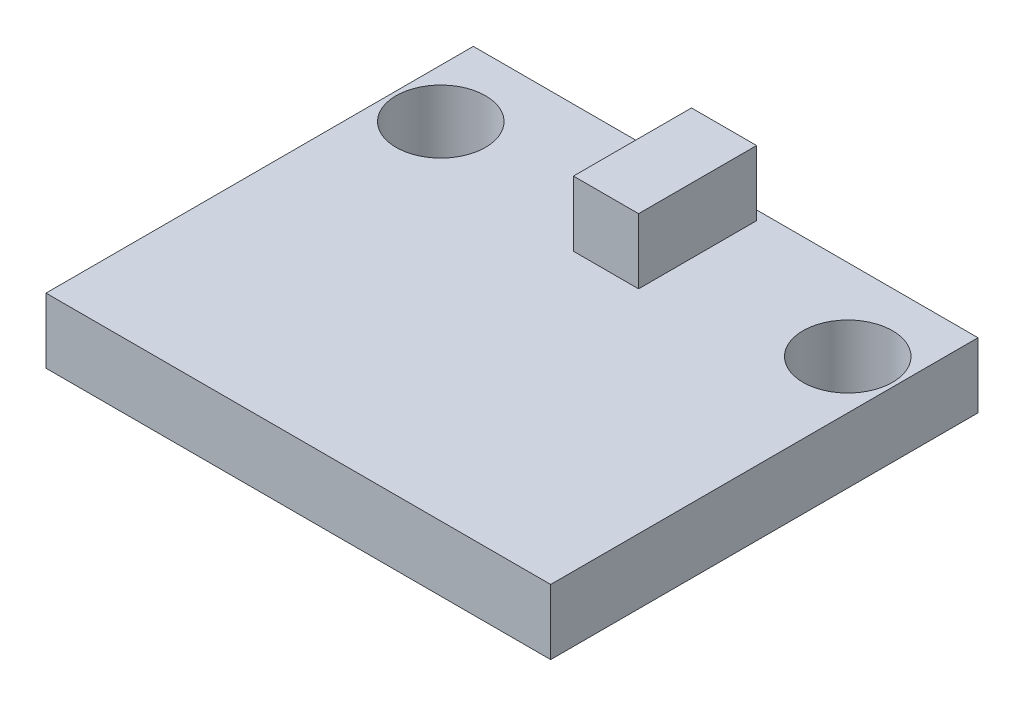
from build123d import *

# Parameters (mm, degrees)
SKETCH1_W           = 12.4
SKETCH1_H           = 10.5
BOSS_EXTRUDE1_DEPTH = 1.6
SKETCH2_R           = 1.1
CUT_EXTRUDE1_DEPTH  = 12.008383169
SKETCH3_W           = 1.6
SKETCH3_H           = 2.9
BOSS_EXTRUDE2_DEPTH = 1.6


with BuildPart() as part:
    # Sketch1 → Boss-Extrude1 (new body)
    with BuildSketch(Plane(origin=(0, 0, 0), x_dir=(1, 0, 0), z_dir=(0, 1, 0))):
        with Locations((-0.19, -3.57)):
            Rectangle(SKETCH1_W, SKETCH1_H)
    extrude(amount=BOSS_EXTRUDE1_DEPTH)

    # Sketch2 → Cut-Extrude1 (cut, through all)
    with BuildSketch(Plane(origin=(0, 0, 0), x_dir=(1, 0, 0), z_dir=(0, 1, 0))):
        with Locations((4.81, -0.32)):
            Circle(SKETCH2_R)
        with Locations((-5.19, -0.32)):
            Circle(SKETCH2_R)
    extrude(amount=CUT_EXTRUDE1_DEPTH, mode=Mode.SUBTRACT)


with BuildPart() as body_2:
    # Sketch3 → Boss-Extrude2 (new body)
    with BuildSketch(Plane(origin=(0, 1.6, 0), x_dir=(1, 0, 0), z_dir=(0, 1, 0))):
        Rectangle(SKETCH3_W, SKETCH3_H)
    extrude(amount=BOSS_EXTRUDE2_DEPTH)


solid = Compound([part.part, body_2.part])
